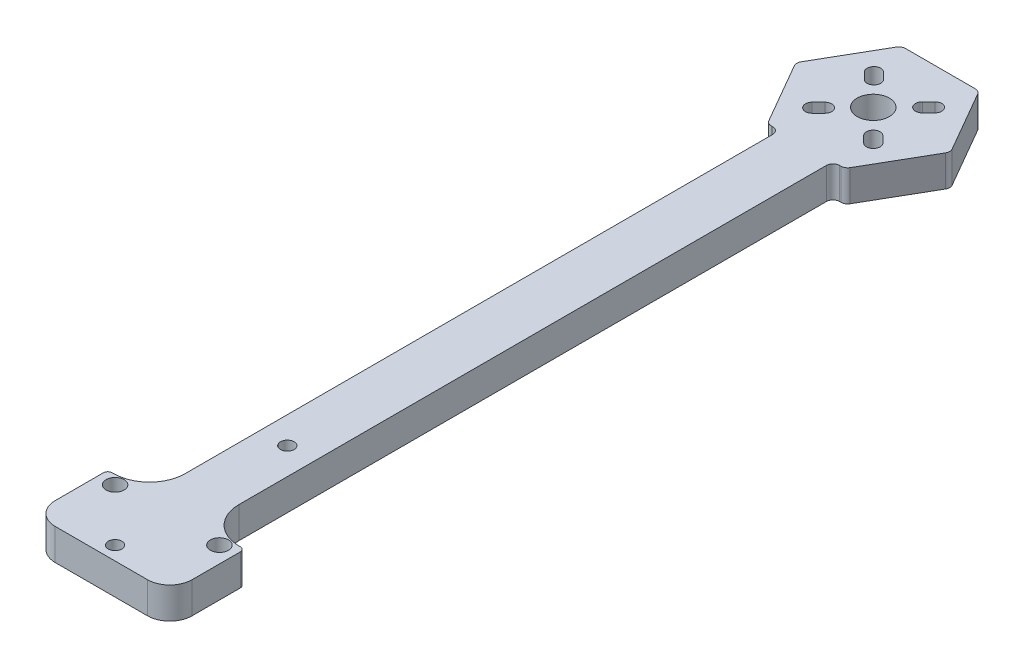
from build123d import *

# Parameters (mm, degrees)
SKETCH_1_R          = 1.52
EXTRUDE_1_DEPTH     = 7
SKETCH_2_R          = 1.52
SKETCH_2_R_2        = 1.520000001
CUT_EXTRUDE_2_DEPTH = 10
FILLET_1_R          = 8
FILLET_3_R          = 1
FILLET_4_R          = 5
FILLET_5_R          = 1.5
SKETCH_3_R          = 2.02
SKETCH_3_R_2        = 1.52
CUT_EXTRUDE_3_DEPTH = 10


with BuildPart() as part:
    # 草图1 → 凸台-拉伸1 (new body)
    with BuildSketch(Plane(origin=(0, 0, 0), x_dir=(1, 0, 0), z_dir=(0, 1, 0))):
        Polygon((12, -0.002444932), (12, 140.81), (30.355391701, 140.81), (30.355391701, 181.996219272), (-18.063025957, 181.996219272), (-18.063025957, 140.81), (0, 140.81), (0, -0.002444932), (-9.306341863, -0.002444932), (-9.306341863, -16.766517892), (21.308530359, -16.766517892), (21.308530359, -0.002444932), align=None)
        with Locations((6, 24.810293178)):
            Circle(SKETCH_1_R, mode=Mode.SUBTRACT)
    extrude(amount=EXTRUDE_1_DEPTH)

    # 草图2 → 切除-拉伸2 (cut)
    with BuildSketch(Plane(origin=(0, 7, 0), x_dir=(1, 0, 0), z_dir=(0, 1, 0))):
        with BuildLine():
            ThreePointArc((9.6, 155.810000018), (3.454415588, 158.35558443), (6, 152.210000018))
            Line((6, 152.210000018), (6, 155.810000018))
            Line((6, 155.810000018), (9.6, 155.810000018))
        make_face()
        with BuildLine():
            Line((6, 155.810000018), (6, 152.210000018))
            ThreePointArc((6, 152.210000018), (7.377660354, 152.4840337), (8.545584409, 153.264415603))
            Line((8.545584409, 153.264415603), (6, 155.810000018))
        make_face()
        with BuildLine():
            Line((9.6, 155.810000018), (6, 155.810000018))
            Line((6, 155.810000018), (8.545584409, 153.264415603))
            ThreePointArc((8.545584409, 153.264415603), (9.325966316, 154.43233966), (9.6, 155.810000018))
        make_face()
        with Locations((-0.748108245, 148.915708883)):
            Circle(SKETCH_2_R)
        with Locations((0.666105318, 150.329922446)):
            Circle(SKETCH_2_R)
        with BuildLine():
            Line((-0.40869699, 151.404724753), (-1.822910552, 149.990511191))
            ThreePointArc((-1.822910552, 149.990511191), (-1.376757591, 150.299616395), (-0.850445717, 150.432259918))
            ThreePointArc((-0.850445717, 150.432259918), (-0.717802194, 150.958571792), (-0.40869699, 151.404724753))
        make_face()
        with BuildLine():
            ThreePointArc((0.76844279, 148.813371411), (0.635799267, 148.287059538), (0.326694063, 147.840906576))
            Line((0.326694063, 147.840906576), (1.740907625, 149.255120138))
            ThreePointArc((1.740907625, 149.255120138), (1.294754663, 148.946014934), (0.76844279, 148.813371411))
        make_face()
        with BuildLine():
            Line((10.405275239, 149.255120151), (11.819488799, 147.840906587))
            ThreePointArc((11.819488799, 147.840906586), (11.510383595, 148.287059549), (11.377740072, 148.813371422))
            ThreePointArc((11.377740072, 148.813371422), (10.851428199, 148.946014947), (10.405275239, 149.255120151))
        make_face()
        with BuildLine():
            Line((11.480077548, 150.329922457), (10.405275241, 151.404724766))
            ThreePointArc((10.405275241, 151.404724766), (9.960077548, 150.329922459), (10.405275239, 149.255120151))
            ThreePointArc((10.405275239, 149.255120151), (10.851428199, 148.946014947), (11.377740072, 148.813371422))
            ThreePointArc((11.377740072, 148.813371422), (11.471198506, 149.449757066), (11.819488801, 149.990511203))
            Line((11.819488801, 149.990511203), (11.480077548, 150.329922457))
        make_face()
        with BuildLine():
            Line((12.554879856, 151.404724763), (11.480077548, 150.329922457))
            Line((11.480077548, 150.329922457), (11.819488801, 149.990511203))
            ThreePointArc((11.819488801, 149.990511203), (12.360242939, 150.338801496), (12.996628583, 150.432259929))
            ThreePointArc((12.996628583, 150.432259929), (12.863985059, 150.958571802), (12.554879856, 151.404724763))
        make_face()
        with BuildLine():
            Line((11.819488801, 149.990511203), (12.554879854, 149.255120148))
            ThreePointArc((12.554879854, 149.255120148), (12.884374437, 149.748243639), (13.000077548, 150.329922457))
            ThreePointArc((13.000077548, 150.329922457), (12.999215062, 150.381120244), (12.996628583, 150.432259929))
            ThreePointArc((12.996628583, 150.432259929), (12.360242939, 150.338801496), (11.819488801, 149.990511203))
        make_face()
        with BuildLine():
            ThreePointArc((11.377740072, 148.813371422), (12.014125716, 148.906829855), (12.554879854, 149.255120148))
            Line((12.554879854, 149.255120148), (11.819488801, 149.990511203))
            ThreePointArc((11.819488801, 149.990511203), (11.471198506, 149.449757066), (11.377740072, 148.813371422))
        make_face()
        with BuildLine():
            ThreePointArc((12.554879856, 151.404724763), (11.480077549, 151.849922457), (10.405275241, 151.404724766))
            Line((10.405275241, 151.404724766), (11.480077548, 150.329922457))
            Line((11.480077548, 150.329922457), (12.554879856, 151.404724763))
        make_face()
        with BuildLine():
            Line((13.969093417, 149.990511199), (12.554879856, 151.404724763))
            ThreePointArc((12.554879856, 151.404724763), (12.863985059, 150.958571802), (12.996628583, 150.432259929))
            ThreePointArc((12.996628583, 150.432259929), (13.522940456, 150.299616405), (13.969093418, 149.9905112))
        make_face()
        with BuildLine():
            Line((12.554879854, 149.255120148), (12.894291108, 148.915708893))
            Line((12.894291108, 148.915708893), (13.969093417, 149.990511199))
            ThreePointArc((13.969093418, 149.9905112), (13.522940456, 150.299616405), (12.996628583, 150.432259929))
            ThreePointArc((12.996628583, 150.432259929), (12.999215062, 150.381120244), (13.000077548, 150.329922457))
            ThreePointArc((13.000077548, 150.329922457), (12.884374437, 149.748243639), (12.554879854, 149.255120148))
        make_face()
        with BuildLine():
            Line((12.894291108, 148.915708893), (13.969093415, 147.840906584))
            ThreePointArc((13.969093415, 147.840906584), (14.298587998, 148.334030075), (14.414291109, 148.915708893))
            ThreePointArc((14.414291109, 148.915708893), (14.298587999, 149.49738771), (13.969093418, 149.9905112))
            Line((13.969093417, 149.990511199), (12.894291108, 148.915708893))
        make_face()
        with Locations((11.480077548, 161.290077579)):
            Circle(SKETCH_2_R)
        with Locations((12.894291108, 162.704291143)):
            Circle(SKETCH_2_R_2)
        with BuildLine():
            ThreePointArc((11.377740072, 162.806628614), (11.510383595, 163.332940488), (11.819488799, 163.77909345))
            Line((11.819488799, 163.779093449), (10.405275239, 162.364879885))
            ThreePointArc((10.405275239, 162.364879885), (10.851428199, 162.673985089), (11.377740072, 162.806628614))
        make_face()
        with BuildLine():
            ThreePointArc((12.996628583, 161.187740107), (12.863985059, 160.661428234), (12.554879856, 160.215275273))
            Line((12.554879856, 160.215275273), (13.969093417, 161.629488837))
            ThreePointArc((13.969093418, 161.629488836), (13.522940456, 161.320383631), (12.996628583, 161.187740107))
        make_face()
        with Locations((0.666105329, 161.290077566)):
            Circle(SKETCH_2_R)
        with Locations((-0.74810823, 162.704291131)):
            Circle(SKETCH_2_R)
        with BuildLine():
            Line((1.740907642, 162.364879874), (0.326694079, 163.779093436))
            ThreePointArc((0.326694079, 163.779093436), (0.635799282, 163.332940474), (0.768442805, 162.8066286))
            ThreePointArc((0.768442805, 162.8066286), (1.294754678, 162.673985076), (1.740907639, 162.364879871))
        make_face()
        with BuildLine():
            ThreePointArc((-0.850445706, 161.187740096), (-1.376757579, 161.320383621), (-1.82291054, 161.629488826))
            Line((-1.82291054, 161.629488826), (-0.408696978, 160.215275263))
            ThreePointArc((-0.408696981, 160.21527526), (-0.717802184, 160.661428223), (-0.850445706, 161.187740096))
        make_face()
        Polygon((-18.063025957, 181.996219272), (-18.063025957, 140.81), (-2.660254048, 140.81), (-11.320508097, 155.810000018), (-2.660254048, 170.810000036), (14.660254048, 170.810000036), (23.320508097, 155.810000018), (16.980762117, 144.829237874), (14.660254048, 140.81), (30.355391701, 140.81), (30.355391701, 181.996219272), align=None)
        with BuildLine():
            ThreePointArc((11.819488799, 147.840906586), (12.894291106, 147.395708892), (13.969093415, 147.840906584))
            Line((13.969093415, 147.840906584), (12.894291108, 148.915708893))
            Line((12.894291108, 148.915708893), (12.554879854, 149.255120148))
            ThreePointArc((12.554879854, 149.255120148), (12.014125716, 148.906829855), (11.377740072, 148.813371422))
            ThreePointArc((11.377740072, 148.813371422), (11.510383595, 148.287059549), (11.819488799, 147.840906586))
        make_face()
    extrude(amount=-CUT_EXTRUDE_2_DEPTH, mode=Mode.SUBTRACT)

    # 圆角1
    fillet_1_edges = [part.edges().sort_by_distance(p)[0] for p in [
        (0, 3.5, 0.002444932),
        (12, 3.5, 0.002444932),
    ]]
    fillet(fillet_1_edges, radius=FILLET_1_R)

    # 圆角3
    fillet_3_edges = [part.edges().sort_by_distance(p)[0] for p in [
        (-9.306341863, 3.5, 0.002444932),
        (21.308530359, 3.5, 0.002444932),
    ]]
    fillet(fillet_3_edges, radius=FILLET_3_R)

    # 圆角4
    fillet_4_edges = [part.edges().sort_by_distance(p)[0] for p in [
        (21.308530359, 3.5, 16.766517892),
        (-9.306341863, 3.5, 16.766517892),
    ]]
    fillet(fillet_4_edges, radius=FILLET_4_R)

    # 圆角5
    fillet_5_edges = [part.edges().sort_by_distance(p)[0] for p in [
        (0, 3.5, -140.81),
        (12, 3.5, -140.81),
        (-11.320508097, 3.5, -155.810000018),
        (-2.660254048, 3.5, -140.81),
        (14.660254048, 3.5, -140.81),
        (23.320508097, 3.5, -155.810000018),
        (14.660254048, 3.5, -170.810000036),
        (-2.660254048, 3.5, -170.810000036),
    ]]
    fillet(fillet_5_edges, radius=FILLET_5_R)

    # 草图3 → 切除-拉伸3 (cut)
    with BuildSketch(Plane(origin=(0, 0, 0), x_dir=(-1, 0, 0), z_dir=(0, -1, 0))):
        with Locations((-17.66726189, -2.022444932)):
            Circle(SKETCH_3_R)
        with Locations((5.66726189, -2.022444932)):
            Circle(SKETCH_3_R)
        with Locations((-6, -13.689706822)):
            Circle(SKETCH_3_R_2)
    extrude(amount=-CUT_EXTRUDE_3_DEPTH, mode=Mode.SUBTRACT)


solid = part.part
